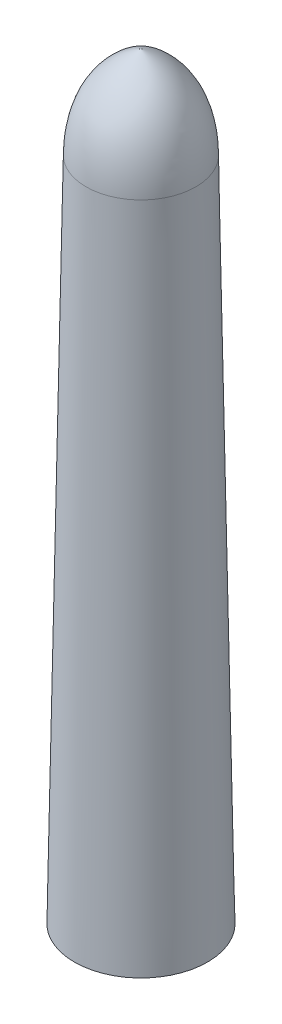
from build123d import *

# Parameters (mm, degrees)
SKETCH1_R           = 20
BOSS_EXTRUDE1_DEPTH = 200
BOSS_EXTRUDE1_TAPER = 1
SKETCH3_R           = 18
CUT_EXTRUDE1_DEPTH  = 200
CUT_EXTRUDE1_TAPER  = 1


with BuildPart() as part:
    # Sketch1 → Boss-Extrude1 (new body)
    with BuildSketch(Plane(origin=(0, 0, 0), x_dir=(1, 0, 0), z_dir=(0, 1, 0))):
        Circle(SKETCH1_R)
    extrude(amount=BOSS_EXTRUDE1_DEPTH, taper=BOSS_EXTRUDE1_TAPER)

    # Sketch3 → Cut-Extrude1 (cut)
    with BuildSketch(Plane.XZ):
        Circle(SKETCH3_R)
    extrude(amount=-CUT_EXTRUDE1_DEPTH, taper=CUT_EXTRUDE1_TAPER, mode=Mode.SUBTRACT)

    # Sketch4 → Revolve1 (revolve)
    with BuildSketch(Plane.XY):
        with BuildLine():
            Line((0, 227.660840397), (0, 225.660840397))
            add(Edge.make_bspline(
                [(0, 225.660840397), (3.662215859, 224.429250128), (11.624405947, 218.277965679), (14.357854187, 208.68709829), (14.508987014, 200)],
                knots=[0, 0, 0, 0, 0.332210555, 1, 1, 1, 1], degree=3))
            Line((14.508987014, 200), (16.508987014, 200))
            add(Edge.make_bspline(
                [(0, 227.660840397), (16.165150369, 220.569430353), (16.508987014, 200)],
                knots=[0, 0, 0, 1, 1, 1], degree=2))
        make_face()
    revolve(axis=Axis((0, 220.606902542, 0), (0, -1, 0)))


solid = part.part
